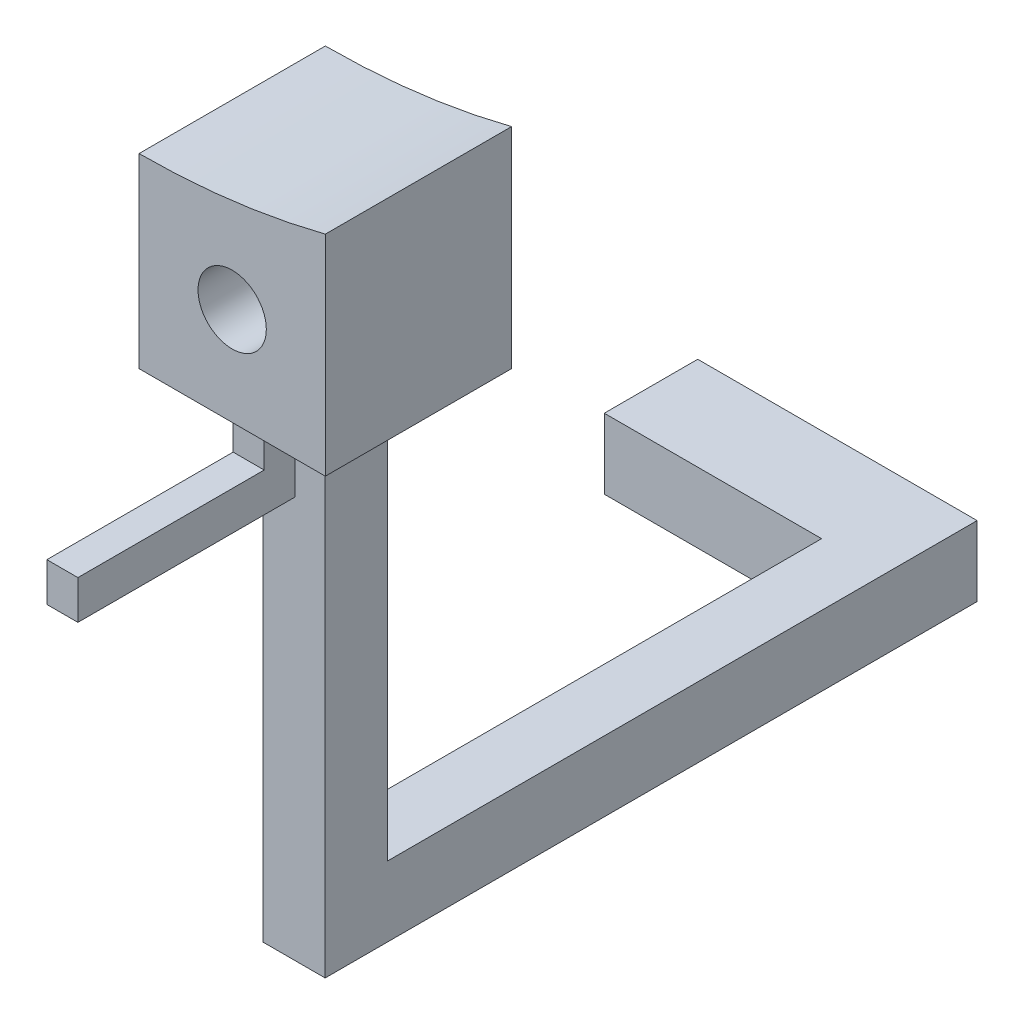
from build123d import *

# Parameters (mm, degrees)
SKETCH1_R           = 1.1
BOSS_EXTRUDE1_DEPTH = 6
SKETCH2_W           = 2
SKETCH2_H           = 2
BOSS_EXTRUDE2_DEPTH = 16
SKETCH4_W           = 2
SKETCH4_H           = 11.994112908
BOSS_EXTRUDE4_DEPTH = 19
SKETCH5_W           = 1
SKETCH5_H           = 1
BOSS_EXTRUDE5_DEPTH = 2.5
SKETCH6_W           = 1
SKETCH6_H           = 1.25
BOSS_EXTRUDE6_DEPTH = 6
SKETCH7_W           = 3.009444154
SKETCH7_H           = 11.994112908
BOSS_EXTRUDE7_DEPTH = 7
SKETCH8_R           = 1.1
BOSS_EXTRUDE8_DEPTH = 1
SKETCH9_R           = 1.1
CUT_EXTRUDE1_DEPTH  = 10
SKETCH10_W          = 19
SKETCH10_H          = 9.734535385
CUT_EXTRUDE2_DEPTH  = 10


with BuildPart() as part:
    # Sketch1 → Boss-Extrude1 (new body)
    with BuildSketch(Plane.XY):
        with BuildLine():
            Line((0, -24.3), (0, -30.3))
            Line((0, -30.3), (6, -30.3))
            Line((6, -30.3), (6, -23.547611344))
            ThreePointArc((6, -23.547611344), (3.023495026, -24.111169151), (0, -24.3))
        make_face()
        with Locations((3, -27.152103588)):
            Circle(SKETCH1_R, mode=Mode.SUBTRACT)
    extrude(amount=BOSS_EXTRUDE1_DEPTH)

    # Sketch2 → Boss-Extrude2 (add)
    with BuildSketch(Plane.XZ.offset(30.3)):
        with Locations((2.994992787, 3)):
            Rectangle(SKETCH2_W, SKETCH2_H)
    extrude(amount=BOSS_EXTRUDE2_DEPTH)

    # Sketch4 → Boss-Extrude4 (add)
    with BuildSketch(Plane(origin=(0, 0, 2), x_dir=(-1, 0, 0), z_dir=(0, 0, -1))):
        with Locations((-2.994992787, -40.302943546)):
            Rectangle(SKETCH4_W, SKETCH4_H)
    extrude(amount=BOSS_EXTRUDE4_DEPTH)

    # Sketch5 → Boss-Extrude5 (add)
    with BuildSketch(Plane.XZ.offset(30.3)):
        with Locations((3.093546014, 5.062561083)):
            Rectangle(SKETCH5_W, SKETCH5_H)
    extrude(amount=BOSS_EXTRUDE5_DEPTH)

    # Sketch6 → Boss-Extrude6 (add)
    with BuildSketch(Plane.XY.offset(5.562561083)):
        with Locations((3.093546014, -32.175)):
            Rectangle(SKETCH6_W, SKETCH6_H)
    extrude(amount=BOSS_EXTRUDE6_DEPTH)

    # Sketch7 → Boss-Extrude7 (add)
    with BuildSketch(Plane.ZY.offset(-1.994992787)):
        with Locations((-15.495277923, -40.302943546)):
            Rectangle(SKETCH7_W, SKETCH7_H)
    extrude(amount=BOSS_EXTRUDE7_DEPTH)

    # Sketch8 → Boss-Extrude8 (add)
    with BuildSketch(Plane(origin=(0, 0, 0), x_dir=(-1, 0, 0), z_dir=(0, 0, -1))):
        with Locations((-3, -27.152103588)):
            Circle(SKETCH8_R)
    extrude(amount=-BOSS_EXTRUDE8_DEPTH)

    # Sketch9 → Cut-Extrude1 (cut)
    with BuildSketch(Plane.XY.offset(6)):
        with Locations((3, -27.152103588)):
            Circle(SKETCH9_R)
    extrude(amount=-CUT_EXTRUDE1_DEPTH, mode=Mode.SUBTRACT)

    # Sketch10 → Cut-Extrude2 (cut)
    with BuildSketch(Plane.ZY.offset(5.005007213)):
        with Locations((-7.5, -39.173154784)):
            Rectangle(SKETCH10_W, SKETCH10_H)
    extrude(amount=-CUT_EXTRUDE2_DEPTH, mode=Mode.SUBTRACT)


solid = part.part
